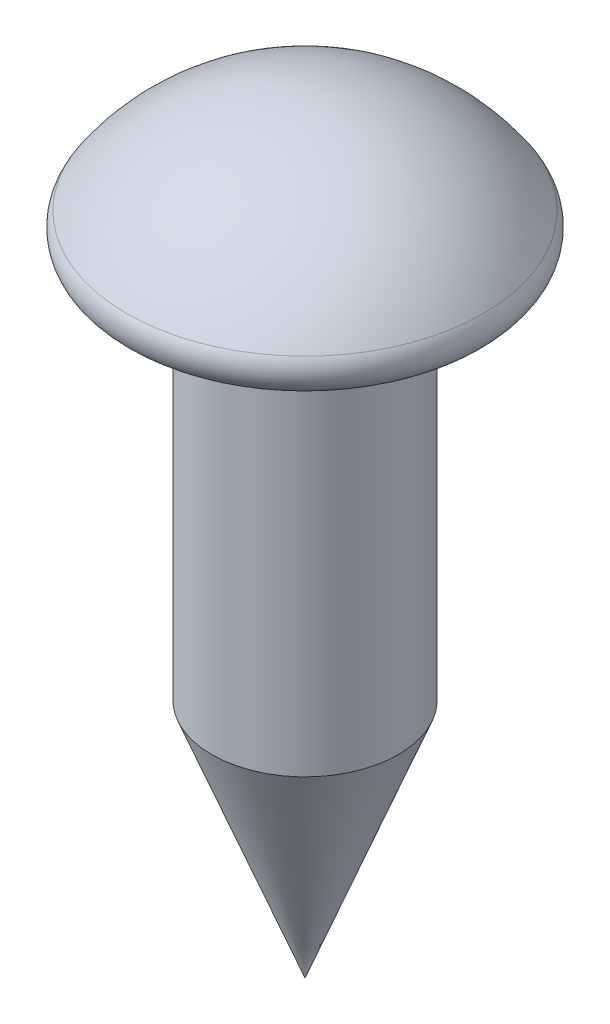
from build123d import *

# Parameters (mm, degrees)
SKETCH1_W = 1.4224
SKETCH1_H = 5.867304468


with BuildPart() as part:
    # Sketch1 → Revolve5 (revolve)
    with BuildSketch(Plane.XY):
        with BuildLine():
            Line((0, 2.032), (0, 0))
            Line((0, 0), (1.4224, 0))
            Line((1.4224, 0), (2.4003, 0))
            ThreePointArc((2.4003, 0), (2.737066528, 0.202816652), (2.71529311, 0.595336979))
            ThreePointArc((2.71529311, 0.595336979), (1.535970159, 1.6507001), (0, 2.032))
        make_face()
        with Locations((0.7112, -2.933652234)):
            Rectangle(SKETCH1_W, SKETCH1_H)
        Polygon((1.4224, -5.867304468), (0, -5.867304468), (0, -9.525), align=None)
    revolve(axis=Axis((0, 2.032, 0), (0, -1, 0)))


solid = part.part
